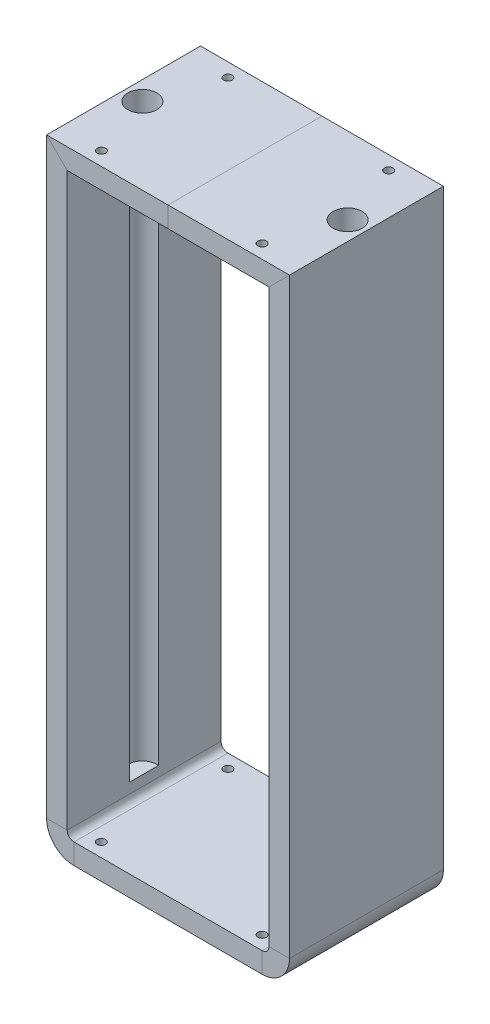
from build123d import *

# Parameters (mm, degrees)
SKETCH6_W          = 90
SKETCH6_H          = 12
SKETCH7_R          = 8.5
SKETCH7_R_2        = 2.5
CUT_EXTRUDE1_DEPTH = 340
SKETCH8_R          = 2.5
CUT_EXTRUDE2_DEPTH = 8


with BuildPart() as part:
    # Sweep2: sweep along a path in Sketch4
    with BuildLine(Plane.XY) as sweep2_path:
        Line((-65, 350), (-65, 10))
        ThreePointArc((-65, 10), (-62.071067812, 2.928932188), (-55, 0))
        Line((-55, 0), (55, 0))
        ThreePointArc((55, 0), (62.071067812, 2.928932188), (65, 10))
        Line((65, 10), (65, 350))
        Line((65, 350), (-65, 350))
    # Sketch6 → Sweep2 (sweep)
    with BuildSketch(Plane(origin=(0, 0, 0), x_dir=(0, 0, -1), z_dir=(1, 0, 0))):
        with Locations((0, 350)):
            Rectangle(SKETCH6_W, SKETCH6_H)
    sweep(path=sweep2_path.line, transition=Transition.RIGHT)

    # Sketch7 → Cut-Extrude1 (cut)
    with BuildSketch(Plane(origin=(0, 356, 0), x_dir=(1, 0, 0), z_dir=(0, 1, 0))):
        with Locations((60, 0)):
            Circle(SKETCH7_R)
        with Locations((-60, 0)):
            Circle(SKETCH7_R)
        with Locations((-47, -37)):
            Circle(SKETCH7_R_2)
        with Locations((-47, 37)):
            Circle(SKETCH7_R_2)
        with Locations((47, -37)):
            Circle(SKETCH7_R_2)
        with Locations((47, 37)):
            Circle(SKETCH7_R_2)
    extrude(amount=-CUT_EXTRUDE1_DEPTH, mode=Mode.SUBTRACT)

    # Sketch8 → Cut-Extrude2 (cut)
    with BuildSketch(Plane(origin=(0, 6, 0), x_dir=(1, 0, 0), z_dir=(0, 1, 0))):
        with Locations((47, 37)):
            Circle(SKETCH8_R)
        with Locations((-47, 37)):
            Circle(SKETCH8_R)
        with Locations((-47, -37)):
            Circle(SKETCH8_R)
        with Locations((47, -37)):
            Circle(SKETCH8_R)
    extrude(amount=-CUT_EXTRUDE2_DEPTH, mode=Mode.SUBTRACT)


solid = part.part
